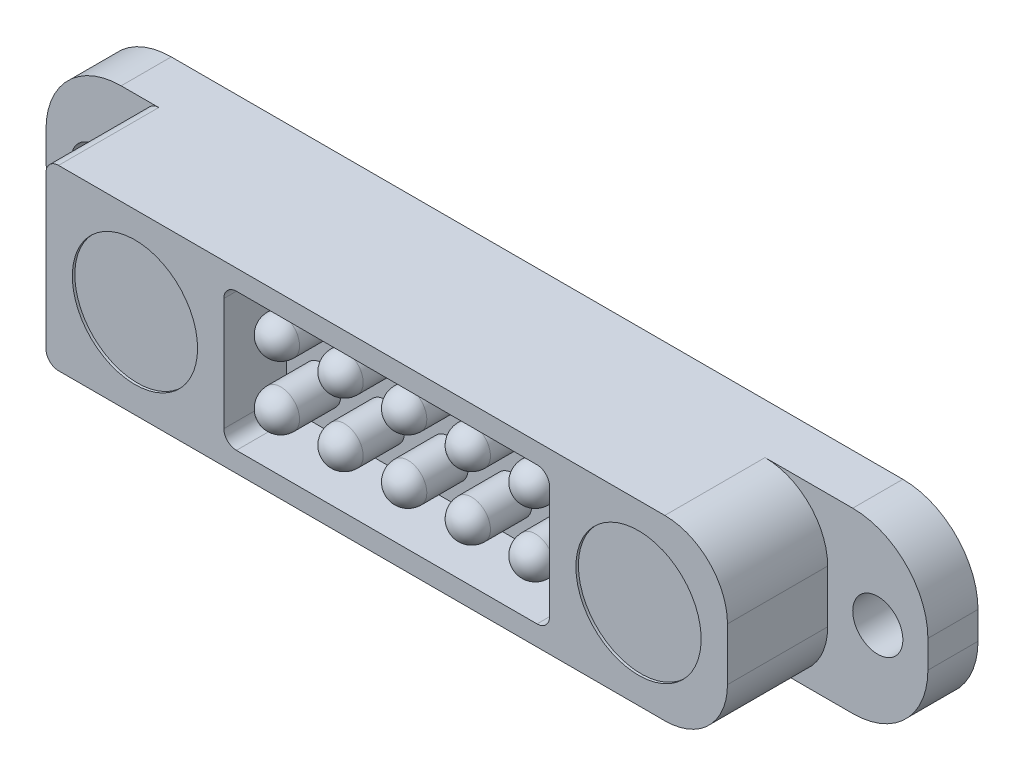
from build123d import *

# Parameters (mm, degrees)
ESQUISSE1_W                      = 35.2
ESQUISSE1_H                      = 7.1
BOSS_EXTRU_1_DEPTH               = 2
CONG_1_R                         = 3
ESQUISSE2_R                      = 1
ENL_V_MAT_EXTRU_1_DEPTH          = 2
ESQUISSE3_W                      = 27.2
ESQUISSE3_H                      = 7.1
BOSS_EXTRU_2_DEPTH               = 4
ESQUISSE4_W                      = 13
ESQUISSE4_H                      = 5.5
ENL_V_MAT_EXTRU_2_DEPTH          = 2.5
CONG_2_R                         = 0.5
ESQUISSE5_R                      = 0.75
BOSS_EXTRU_3_DEPTH               = 2.4
CONG_3_R                         = 0.75
ESQUISSE6_R                      = 0.4
BOSS_EXTRU_4_DEPTH               = 1.758
R_P_TITION_LIN_AIRE1_COUNT       = 2
R_P_TITION_LIN_AIRE1_PITCH       = 2.54
R_P_TITION_LIN_AIRE1_COUNT_DIR2  = 5
R_P_TITION_LIN_AIRE1_PITCH_DIR2  = 2.54
CONG_3_OF_R_P_TITION_LIN_AIRE1_R = 0.75
ESQUISSE7_R                      = 2.5
ENL_V_MAT_EXTRU_3_DEPTH          = 0.1
CONG_4_R                         = 2.5


with BuildPart() as part:
    # Esquisse1 → Boss.-Extru.1 (new body)
    with BuildSketch(Plane.XY):
        Rectangle(ESQUISSE1_W, ESQUISSE1_H)
    extrude(amount=BOSS_EXTRU_1_DEPTH)

    # Congé1
    cong_1_edges = [part.edges().sort_by_distance(p)[0] for p in [
        (-17.6, 3.55, 1),
        (17.6, 3.55, 1),
        (17.6, -3.55, 1),
        (-17.6, -3.55, 1),
    ]]
    fillet(cong_1_edges, radius=CONG_1_R)

    # Esquisse2 → Enlèv. mat.-Extru.1 (cut)
    with BuildSketch(Plane.XY.offset(2)):
        with Locations((-15.6, 0)):
            Circle(ESQUISSE2_R)
    enl_v_mat_extru_1 = extrude(amount=-ENL_V_MAT_EXTRU_1_DEPTH, mode=Mode.SUBTRACT)

    # Symétrie1: Enlèv. mat.-Extru.1 across plane
    add(enl_v_mat_extru_1.mirror(Plane(origin=(0, 0, 0), x_dir=(0, 0, 1), z_dir=(1, 0, 0))), mode=Mode.SUBTRACT)

    # Esquisse3 → Boss.-Extru.2 (add)
    with BuildSketch(Plane.XY.offset(2)):
        Rectangle(ESQUISSE3_W, ESQUISSE3_H)
    extrude(amount=BOSS_EXTRU_2_DEPTH)

    # Esquisse4 → Enlèv. mat.-Extru.2 (cut)
    with BuildSketch(Plane.XY.offset(6)):
        Rectangle(ESQUISSE4_W, ESQUISSE4_H)
    extrude(amount=-ENL_V_MAT_EXTRU_2_DEPTH, mode=Mode.SUBTRACT)

    # Congé2
    cong_2_edges = [part.edges().sort_by_distance(p)[0] for p in [
        (-13.6, 3.55, 4),
        (-13.6, -3.55, 4),
        (-6.5, -2.75, 4.75),
        (-6.5, 2.75, 4.75),
        (6.5, 2.75, 4.75),
        (6.5, -2.75, 4.75),
    ]]
    fillet(cong_2_edges, radius=CONG_2_R)

    # Esquisse5 → Boss.-Extru.3 (add)
    with BuildSketch(Plane.XY.offset(3.5)):
        with Locations((-5.08, 1.27)):
            Circle(ESQUISSE5_R)
    boss_extru_3 = extrude(amount=BOSS_EXTRU_3_DEPTH)

    # Congé3
    cong_3_edges = [part.edges().sort_by_distance(p)[0] for p in [
        (-5.83, 1.27, 5.9),
    ]]
    fillet(cong_3_edges, radius=CONG_3_R)

    # Esquisse6 → Boss.-Extru.4 (add)
    with BuildSketch(Plane(origin=(0, 0, 0), x_dir=(-1, 0, 0), z_dir=(0, 0, -1))):
        with Locations((5.08, 1.27)):
            Circle(ESQUISSE6_R)
    boss_extru_4 = extrude(amount=BOSS_EXTRU_4_DEPTH)

    # Répétition linéaire1: Boss.-Extru.3, Boss.-Extru.4 2 × 5
    with Locations(*[(j * R_P_TITION_LIN_AIRE1_PITCH_DIR2, -i * R_P_TITION_LIN_AIRE1_PITCH, 0) for i in range(R_P_TITION_LIN_AIRE1_COUNT) for j in range(R_P_TITION_LIN_AIRE1_COUNT_DIR2) if (i, j) != (0, 0)]):
        add(boss_extru_3)
        add(boss_extru_4)

    # Congé3 of Répétition linéaire1
    cong_3_of_r_p_tition_lin_aire1_edges = [part.edges().sort_by_distance(p)[0] for p in [
        (-3.29, 1.27, 5.9),
        (-0.75, 1.27, 5.9),
        (1.79, 1.27, 5.9),
        (4.33, 1.27, 5.9),
        (-5.83, -1.27, 5.9),
        (-3.29, -1.27, 5.9),
        (-0.75, -1.27, 5.9),
        (1.79, -1.27, 5.9),
        (4.33, -1.27, 5.9),
    ]]
    fillet(cong_3_of_r_p_tition_lin_aire1_edges, radius=CONG_3_OF_R_P_TITION_LIN_AIRE1_R)

    # Esquisse7 → Enlèv. mat.-Extru.3 (cut)
    with BuildSketch(Plane.XY.offset(6)):
        with Locations((-10.05, 0)):
            Circle(ESQUISSE7_R)
    enl_v_mat_extru_3 = extrude(amount=-ENL_V_MAT_EXTRU_3_DEPTH, mode=Mode.SUBTRACT)

    # Symétrie2: Enlèv. mat.-Extru.3 across plane
    add(enl_v_mat_extru_3.mirror(Plane(origin=(0, 0, 0), x_dir=(0, 0, 1), z_dir=(1, 0, 0))), mode=Mode.SUBTRACT)

    # Congé4
    cong_4_edges = [part.edges().sort_by_distance(p)[0] for p in [
        (13.6, -3.55, 4),
        (13.6, 3.55, 4),
    ]]
    fillet(cong_4_edges, radius=CONG_4_R)


solid = part.part
